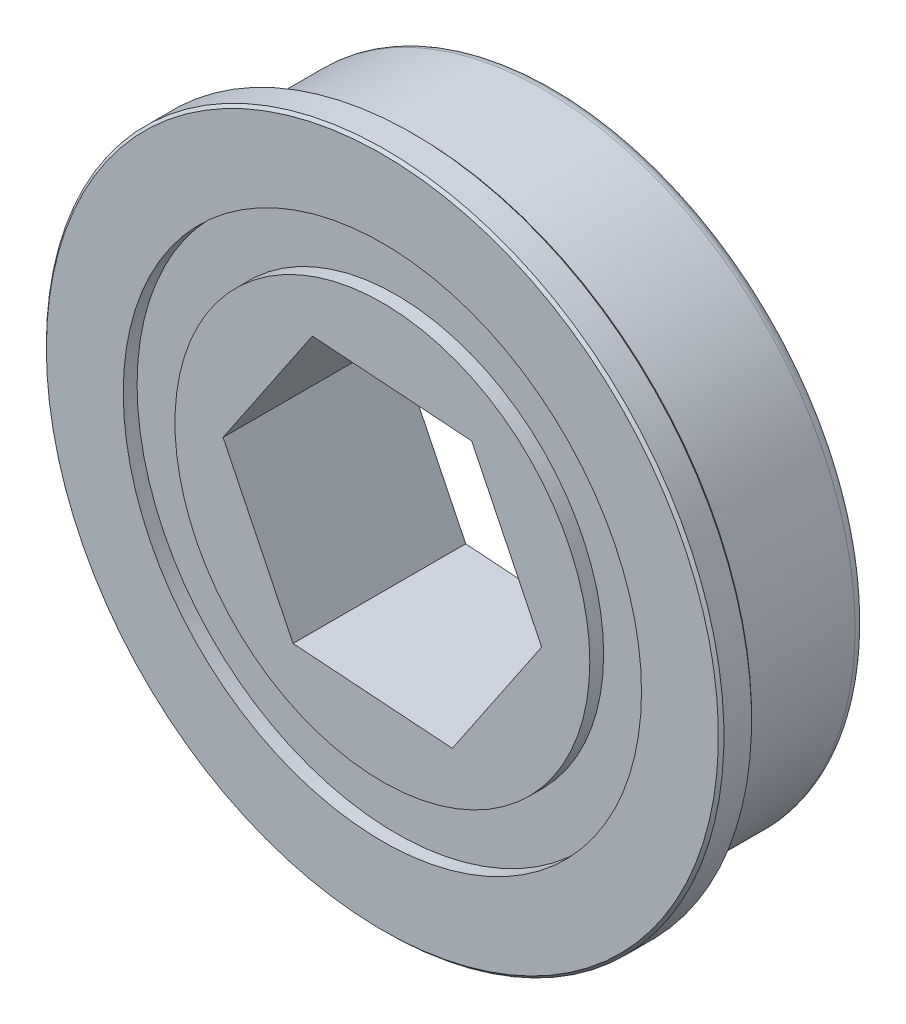
from build123d import *

# Parameters (mm, degrees)
CHAMFER1_SIZE       = 0.127
FILLET2_R           = 0.508
CUT_EXTRUDE2_REACH  = 9.927
SKETCH3_R           = 11.899111158
SKETCH4_R           = 9.525
BOSS_EXTRUDE1_DEPTH = 7.92734
SKETCH5_R           = 11.899111158
SKETCH5_R_2         = 9.525
BOSS_EXTRUDE2_DEPTH = 6.65734


with BuildPart() as part:
    # Sketch1 → Revolve1 (revolve)
    with BuildSketch(Plane.XZ):
        Polygon((15.4305, 7.92734), (0, 7.92734), (0, 0), (14.2875, 0), (14.2875, 5.89534), (13.97, 5.89534), (13.97, 6.40334), (15.5575, 6.40334), (15.5575, 7.80034), align=None)
    revolve(axis=Axis((0, 0, 7.92734), (0, 0, -1)))

    # Chamfer1
    chamfer1_edges = [part.edges().sort_by_distance(p)[0] for p in [
        (-15.5575, 0, 6.40334),
    ]]
    chamfer(chamfer1_edges, length=CHAMFER1_SIZE)

    # Fillet2
    fillet2_edges = [part.edges().sort_by_distance(p)[0] for p in [
        (-14.2875, 0, 0),
    ]]
    fillet(fillet2_edges, radius=FILLET2_R)

    # Sketch3 → Cut-Extrude2 (cut, up to next)
    with BuildSketch(Plane.XY.offset(7.92734), mode=Mode.PRIVATE) as cut_extrude2_sk1:
        Circle(SKETCH3_R)
    cut_extrude2_tool1 = extrude(cut_extrude2_sk1.sketch, amount=-CUT_EXTRUDE2_REACH, mode=Mode.PRIVATE) & part.part
    add(cut_extrude2_tool1.solids().sort_by_distance((0, 0, 7.92734))[0], mode=Mode.SUBTRACT)



with BuildPart() as body_2:
    # Sketch4 → Boss-Extrude1 (new body)
    with BuildSketch(Plane(origin=(0, 0, 0), x_dir=(-1, 0, 0), z_dir=(0, 0, -1))):
        Circle(SKETCH4_R)
        Polygon((-3.212275886, -6.591253065), (4.102054654, -6.077539054), (7.31433054, 0.513714011), (3.212275886, 6.591253065), (-4.102054654, 6.077539054), (-7.31433054, -0.513714011), align=None, mode=Mode.SUBTRACT)
    extrude(amount=-BOSS_EXTRUDE1_DEPTH)


with BuildPart() as part_1:
    add(part.part)

    add(body_2.part)  # Boss-Extrude2 merges body 2
    # Sketch5 → Boss-Extrude2 (add)
    with BuildSketch(Plane(origin=(0, 0, 0.635), x_dir=(-1, 0, 0), z_dir=(0, 0, -1))):
        Circle(SKETCH5_R)
        Circle(SKETCH5_R_2, mode=Mode.SUBTRACT)
    extrude(amount=-BOSS_EXTRUDE2_DEPTH)


solid = part_1.part
